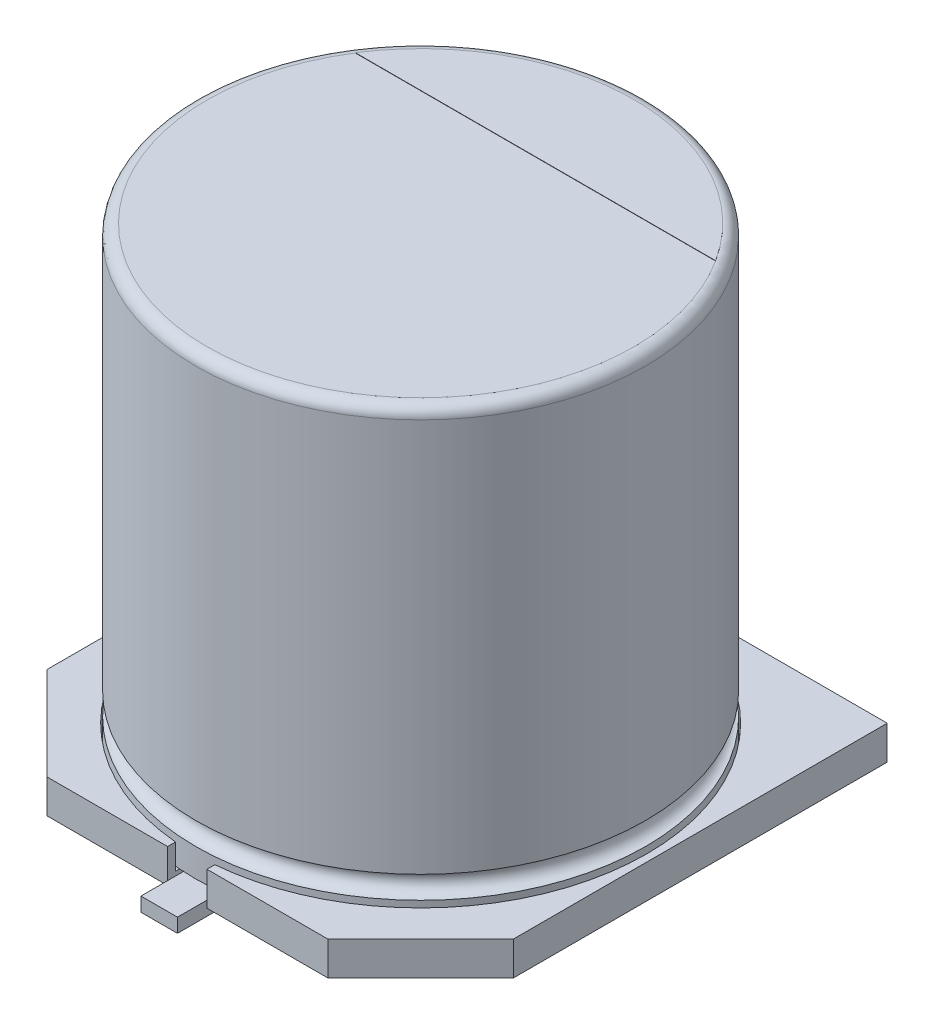
from build123d import *

# Parameters (mm, degrees)
BOSS_EXTRUDE1_DEPTH = 1.2
CUT_EXTRUDE1_START  = 1.2
SKETCH4_R           = 8.05
CUT_EXTRUDE1_DEPTH  = 0.9
BOSS_EXTRUDE2_DEPTH = 0.65
BOSS_EXTRUDE3_DEPTH = 0.01


with BuildPart() as part:
    # Sketch1 → Boss-Extrude1 (new body)
    with BuildSketch(Plane(origin=(0, 0, 0), x_dir=(1, 0, 0), z_dir=(0, 1, 0))):
        Polygon((-8.3, 8.3), (-0.7, 8.3), (-0.7, 7.58827238), (0.7, 7.58827238), (0.7, 8.3), (8.3, 8.3), (8.3, -1.8), (8.3, -5), (5, -8.3), (0.7, -8.3), (0.7, -7.58827238), (-0.7, -7.58827238), (-0.7, -8.3), (-5, -8.3), (-8.3, -5), (-8.3, -1.8), align=None)
    extrude(amount=BOSS_EXTRUDE1_DEPTH)

    # Sketch4 → Cut-Extrude1 (cut)
    with BuildSketch(Plane(origin=(0, 0, 0), x_dir=(1, 0, 0), z_dir=(0, 1, 0)).offset(CUT_EXTRUDE1_START)):
        Circle(SKETCH4_R)
    extrude(amount=-CUT_EXTRUDE1_DEPTH, mode=Mode.SUBTRACT)

    # Sketch5 → Boss-Extrude2 (add, symmetric)
    with BuildSketch(Plane(origin=(0, 0, 0), x_dir=(0, 0, -1), z_dir=(1, 0, 0))):
        with BuildLine():
            Line((-9.3, 0.2), (-9.3, -0.3))
            Line((-9.3, -0.3), (-5.591421356, -0.3))
            ThreePointArc((-5.591421356, -0.3), (-5.553153013, -0.292387953), (-5.520710678, -0.270710678))
            Line((-5.520710678, -0.270710678), (-5.329289322, -0.079289322))
            ThreePointArc((-5.329289322, -0.079289322), (-5.307612047, -0.046846987), (-5.3, -0.008578644))
            Line((-5.3, -0.008578644), (-5.3, 0.2))
            Line((-5.3, 0.2), (-9.3, 0.2))
        make_face()
    boss_extrude2 = extrude(amount=BOSS_EXTRUDE2_DEPTH, both=True)

    # Mirror1: Boss-Extrude2 across plane
    add(boss_extrude2.mirror(Plane.XY))


with BuildPart() as body_2:
    # Sketch3 → Revolve1 (revolve)
    with BuildSketch(Plane.XY):
        with BuildLine():
            Line((-8, 16.2), (-8, 2.2))
            ThreePointArc((-8, 2.2), (-7.6, 1.8), (-8, 1.4))
            Line((-8, 1.4), (-8, 0.4))
            Line((-8, 0.4), (0, 0.4))
            Line((0, 0.4), (0, 16.6))
            Line((0, 16.6), (-7.6, 16.6))
            ThreePointArc((-7.6, 16.6), (-7.882842712, 16.482842712), (-8, 16.2))
        make_face()
    revolve(axis=Axis((0, 22.223469288, 0), (0, -1, 0)))

    # Sketch6 → Boss-Extrude3 (add)
    with BuildSketch(Plane(origin=(0, 16.6, 0), x_dir=(1, 0, 0), z_dir=(0, 1, 0))):
        with BuildLine():
            Line((6.40770054, 4.086731431), (-6.40770054, 4.086731431))
            ThreePointArc((-6.40770054, 4.086731431), (0, 7.6), (6.40770054, 4.086731431))
        make_face()
    extrude(amount=BOSS_EXTRUDE3_DEPTH)


solid = Compound([part.part, body_2.part])
